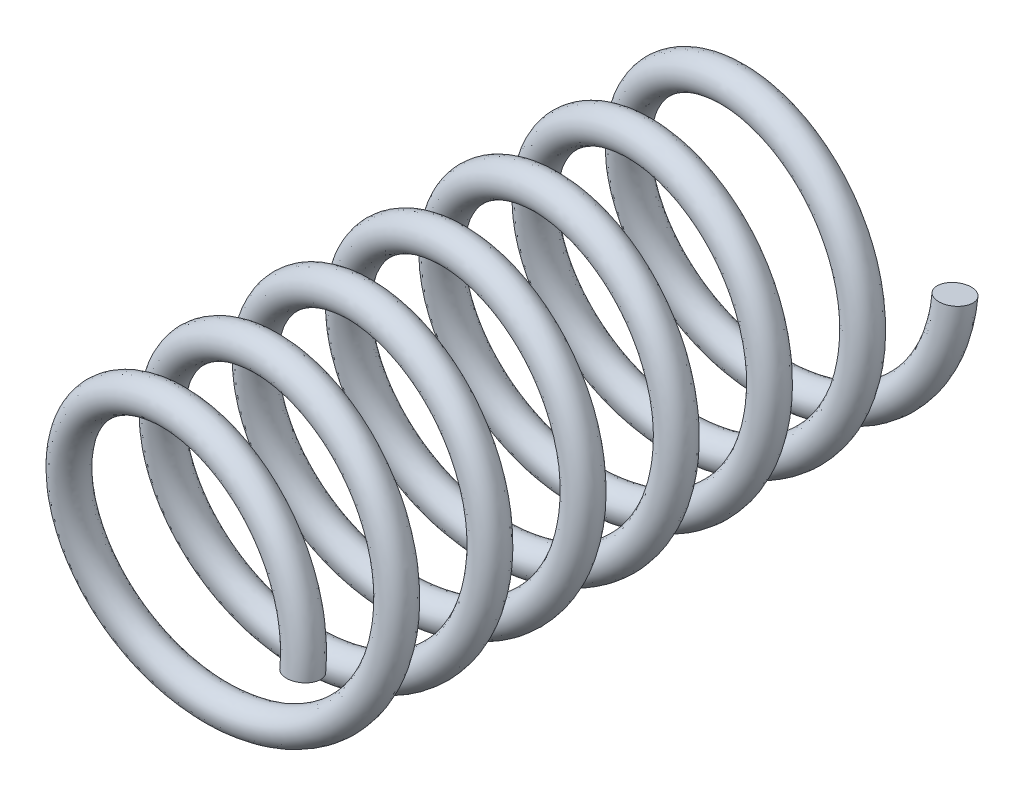
from build123d import *

# Parameters (mm, degrees)
SWEEP1_PITCH     = 12.7
SWEEP1_HEIGHT    = 88.9
SWEEP1_RADIUS    = 19.05
SWEEP1_PROFILE_R = 2.2225


with BuildPart() as part:
    # Sweep1: sweep along a helix
    with BuildLine() as sweep1_path:
        Helix(SWEEP1_PITCH, SWEEP1_HEIGHT, SWEEP1_RADIUS, center=(0, 0, 0), direction=(0, 0, 1), lefthand=True)
    # Sweep1 profile (on start of the path) → Sweep1 (sweep)
    with BuildSketch(Plane(origin=(19.05, 0, 0), x_dir=(0, -0.105511041, -0.994418132), z_dir=(0, -0.994418132, 0.105511041))):
        Circle(SWEEP1_PROFILE_R)
    sweep(path=sweep1_path.line, is_frenet=True)


solid = part.part
